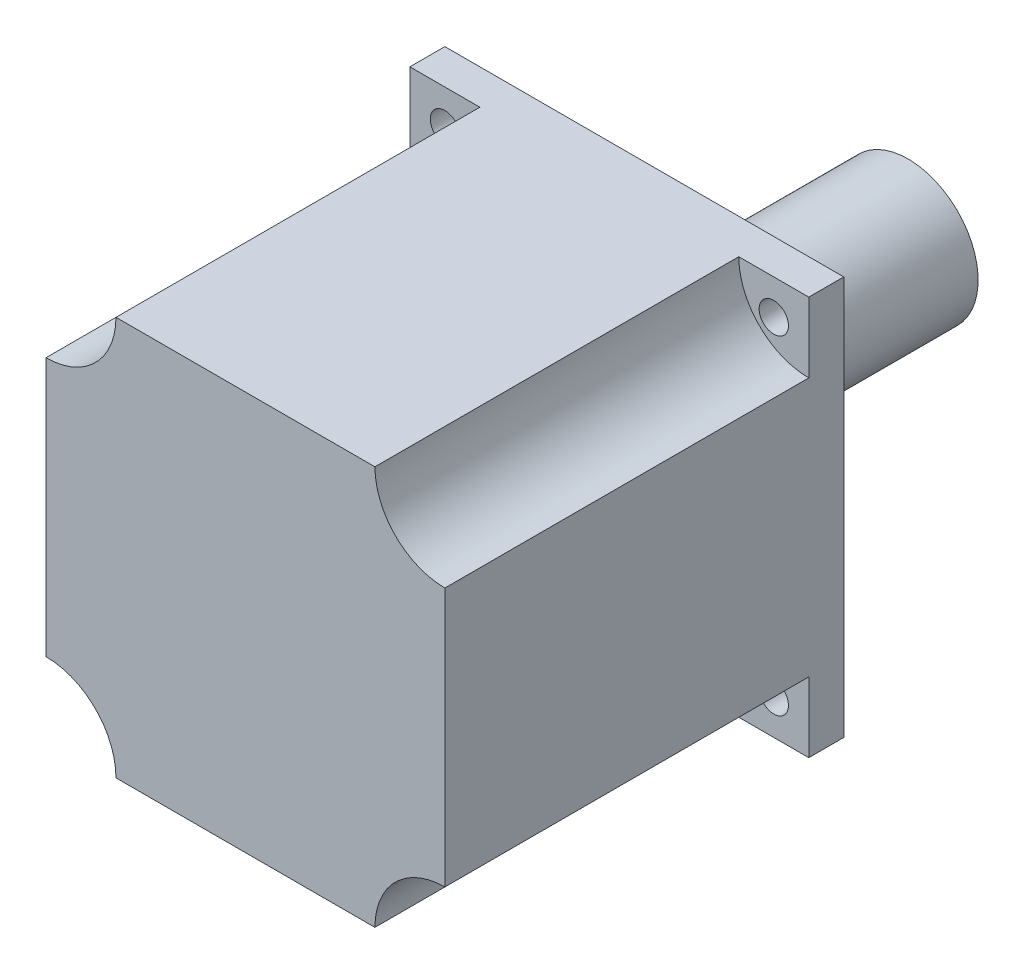
from build123d import *

# Parameters (mm, degrees)
SKETCH_1_W          = 57
SKETCH_1_H          = 57
EXTRUDE_1_DEPTH     = 57
SKETCH_2_R          = 10
CUT_EXTRUDE_1_DEPTH = 52
SKETCH_3_R          = 2.094139209
CUT_EXTRUDE_3_DEPTH = 6
SKETCH_4_R          = 5
EXTRUDE_3_DEPTH     = 11.7
SKETCH_5_R          = 10
EXTRUDE_4_DEPTH     = 26


with BuildPart() as part:
    # 草图1 → 凸台-拉伸1 (new body)
    with BuildSketch(Plane.XY):
        Rectangle(SKETCH_1_W, SKETCH_1_H)
    extrude(amount=EXTRUDE_1_DEPTH)

    # 草图2 → 切除-拉伸1 (cut)
    with BuildSketch(Plane.XY.offset(57)):
        with Locations((28.5, 28.5)):
            Circle(SKETCH_2_R)
        with Locations((-28.5, 28.5)):
            Circle(SKETCH_2_R)
        with Locations((28.5, -28.5)):
            Circle(SKETCH_2_R)
        with Locations((-28.5, -28.5)):
            Circle(SKETCH_2_R)
    extrude(amount=-CUT_EXTRUDE_1_DEPTH, mode=Mode.SUBTRACT)

    # 草图3 → 切除-拉伸3 (cut, through all)
    with BuildSketch(Plane.XY.offset(5)):
        with Locations((23.5, -23.5)):
            Circle(SKETCH_3_R)
        with Locations((-23.5, -23.5)):
            Circle(SKETCH_3_R)
        with Locations((-23.5, 23.5)):
            Circle(SKETCH_3_R)
        with Locations((23.5, 23.5)):
            Circle(SKETCH_3_R)
    extrude(amount=-CUT_EXTRUDE_3_DEPTH, mode=Mode.SUBTRACT)

    # 草图4 → 凸台-拉伸3 (add)
    with BuildSketch(Plane(origin=(0, 0, 0), x_dir=(-1, 0, 0), z_dir=(0, 0, -1))):
        Circle(SKETCH_4_R)
    extrude(amount=EXTRUDE_3_DEPTH)

    # 草图5 → 凸台-拉伸4 (add)
    with BuildSketch(Plane(origin=(0, 0, -11.7), x_dir=(-1, 0, 0), z_dir=(0, 0, -1))):
        Circle(SKETCH_5_R)
    extrude(amount=EXTRUDE_4_DEPTH)


solid = part.part
